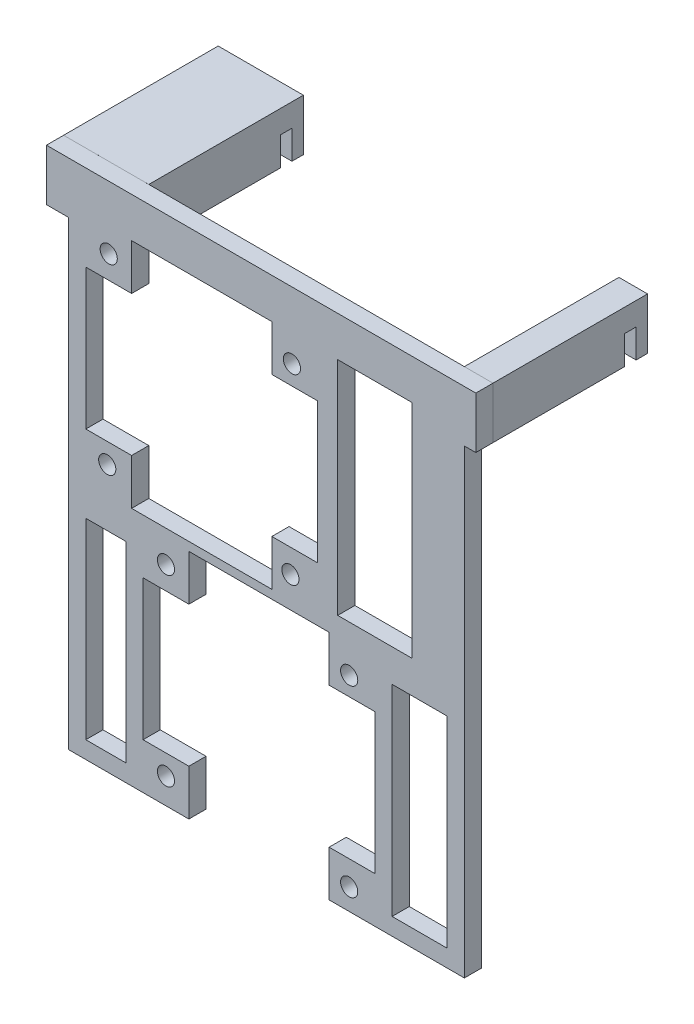
from build123d import *

# Parameters (mm, degrees)
CROQUIS1_W                = 5
CROQUIS1_H                = 9
SALIENTE_EXTRUIR1_DEPTH   = 27
CROQUIS1_W_2              = 14.88
SALIENTE_EXTRUIR1_2_DEPTH = 27
CROQUIS2_R                = 1.5
CROQUIS2_W                = 9.622736673
CROQUIS2_H                = 35.115677267
CROQUIS2_W_2              = 7
CROQUIS2_H_2              = 33.5
CROQUIS2_W_3              = 13
CROQUIS2_H_3              = 38.689553843
SALIENTE_EXTRUIR2_DEPTH   = 3
CORTAR_EXTRUIR1_START     = -75
CROQUIS3_W                = 2
CROQUIS3_H                = 5
CORTAR_EXTRUIR1_DEPTH     = 75


with BuildPart() as part:
    # Croquis1 → Saliente-Extruir1 (new body)
    with BuildSketch(Plane.XY):
        with Locations((27.073193316, 13.235294118)):
            Rectangle(CROQUIS1_W, CROQUIS1_H)
    extrude(amount=SALIENTE_EXTRUIR1_DEPTH)



with BuildPart() as body_2:
    # Croquis1 → Saliente-Extruir1 2 (new body)
    with BuildSketch(Plane.XY):
        with Locations((-37.986806684, 13.235294118)):
            Rectangle(CROQUIS1_W_2, CROQUIS1_H)
    extrude(amount=SALIENTE_EXTRUIR1_2_DEPTH)


with BuildPart() as part_1:
    add(part.part)

    add(body_2.part)  # Saliente-Extruir2 merges body 2
    # Croquis2 → Saliente-Extruir2 (add)
    with BuildSketch(Plane.XY.offset(27)):
        Polygon((-45.425929091, 8.73433808), (-41.548665764, 8.73433808), (-41.548665764, -71.76566192), (-28.548665764, -71.76566192), (-20.548665764, -71.76566192), (-20.548665764, -63.76566192), (-28.548665764, -63.76566192), (-28.548665764, -39.26566192), (-20.548665764, -39.26566192), (-20.548665764, -31.26566192), (3.951334236, -31.26566192), (3.951334236, -39.26566192), (11.951334236, -39.26566192), (11.951334236, -63.76566192), (3.951334236, -63.76566192), (3.951334236, -71.745971947), (15.951334236, -71.745971947), (27.574070909, -71.745971947), (27.574070909, 8.73433808), (29.574070909, 8.73433808), (29.573193316, 17.735294118), (-45.425929091, 17.73433808), align=None)
        with Locations((-24.548665764, -35.26566192)):
            Circle(CROQUIS2_R, mode=Mode.SUBTRACT)
        with Locations((7.451334236, -36.017200949)):
            Circle(CROQUIS2_R, mode=Mode.SUBTRACT)
        with Locations((-24.548665764, -67.26566192)):
            Circle(CROQUIS2_R, mode=Mode.SUBTRACT)
        with Locations((7.451334236, -68.017200949)):
            Circle(CROQUIS2_R, mode=Mode.SUBTRACT)
        with Locations((-34.548665764, 6.73433808)):
            Circle(CROQUIS2_R, mode=Mode.SUBTRACT)
        with Locations((-34.806623414, -25.26566192)):
            Circle(CROQUIS2_R, mode=Mode.SUBTRACT)
        with Locations((-2.806623414, -25.892139455)):
            Circle(CROQUIS2_R, mode=Mode.SUBTRACT)
        with Locations((-2.548665764, 6.107860545)):
            Circle(CROQUIS2_R, mode=Mode.SUBTRACT)
        Polygon((-30.548665764, -29.76566192), (-30.548665764, -21.76566192), (-38.548665764, -21.76566192), (-38.548665764, 2.73433808), (-30.548665764, 2.73433808), (-30.548665764, 10.73433808), (-6.048665764, 10.73433808), (-6.048665764, 2.73433808), (1.951334236, 2.73433808), (1.951334236, -21.76566192), (-6.048665764, -21.76566192), (-6.048665764, -29.76566192), align=None, mode=Mode.SUBTRACT)
        with Locations((19.762702573, -51.188133314)):
            Rectangle(CROQUIS2_W, CROQUIS2_H, mode=Mode.SUBTRACT)
        with Locations((-35.048665764, -52.01566192)):
            Rectangle(CROQUIS2_W_2, CROQUIS2_H_2, mode=Mode.SUBTRACT)
        with Locations((11.951334236, -8.610438842)):
            Rectangle(CROQUIS2_W_3, CROQUIS2_H_3, mode=Mode.SUBTRACT)
    extrude(amount=SALIENTE_EXTRUIR2_DEPTH)

    # Croquis3 → Cortar-Extruir1 (cut)
    with BuildSketch(Plane(origin=(29.573193316, 0, 0), x_dir=(0, 0, -1), z_dir=(1, 0, 0)).offset(CORTAR_EXTRUIR1_START)):
        with Locations((-3, 11.235294118)):
            Rectangle(CROQUIS3_W, CROQUIS3_H)
    extrude(amount=CORTAR_EXTRUIR1_DEPTH, mode=Mode.SUBTRACT)


solid = part_1.part
